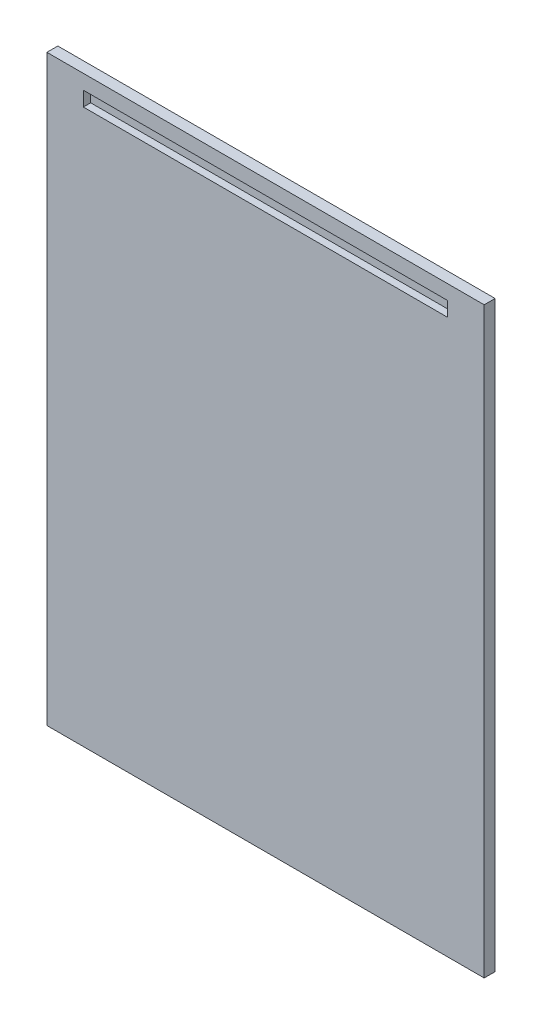
from build123d import *

# Parameters (mm, degrees)
CROQUIS1_W              = 600
CROQUIS1_H              = 800
SALIENTE_EXTRUIR1_DEPTH = 15
CROQUIS2_W              = 500
CROQUIS2_H              = 20
CORTAR_EXTRUIR1_DEPTH   = 10


with BuildPart() as part:
    # Croquis1 → Saliente-Extruir1 (new body)
    with BuildSketch(Plane.XY):
        Rectangle(CROQUIS1_W, CROQUIS1_H)
    extrude(amount=SALIENTE_EXTRUIR1_DEPTH)

    # Croquis2 → Cortar-Extruir1 (cut)
    with BuildSketch(Plane.XY.offset(15)):
        with Locations((0, 370)):
            Rectangle(CROQUIS2_W, CROQUIS2_H)
    extrude(amount=-CORTAR_EXTRUIR1_DEPTH, mode=Mode.SUBTRACT)


solid = part.part
